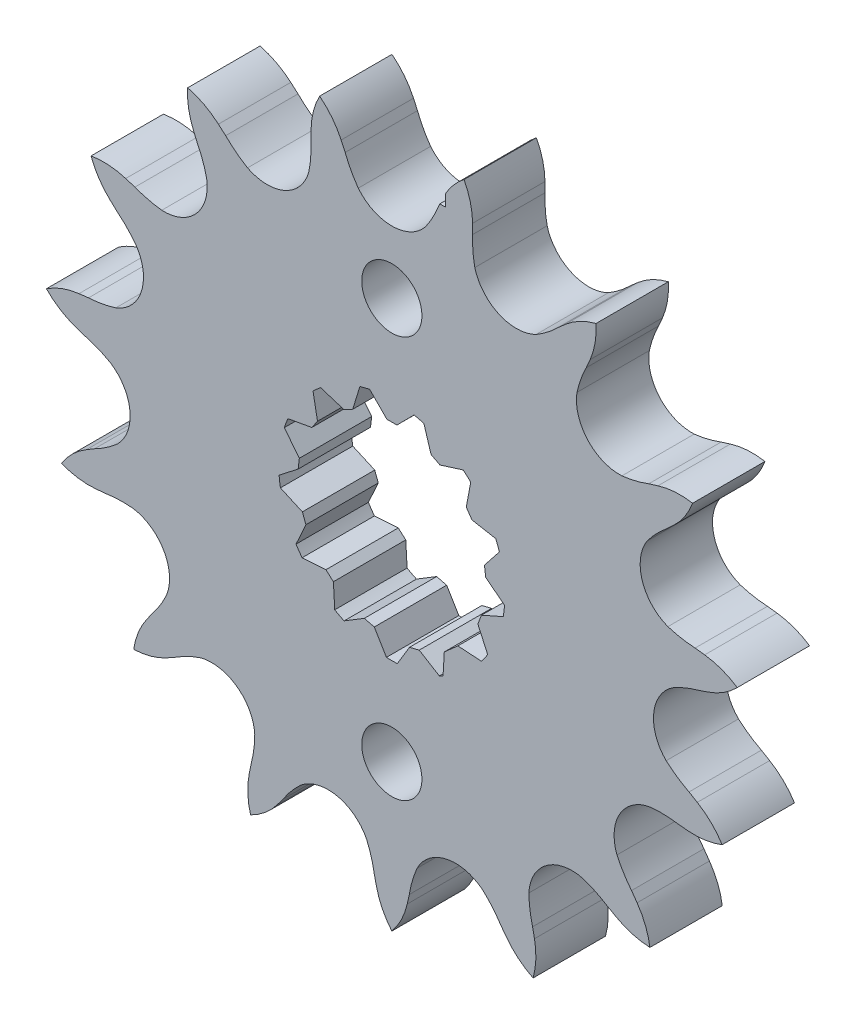
from build123d import *

# Parameters (mm, degrees)
BOSS_EXTRUDE1_DEPTH = 7.21
CUT_EXTRUDE1_DEPTH  = 8.21
SKETCH5_R           = 3
CUT_EXTRUDE2_DEPTH  = 8.21


with BuildPart() as part:
    # Sketch1 → Boss-Extrude1 (new body)
    with BuildSketch(Plane.XY):
        with BuildLine():
            ThreePointArc((-3.344051097, 27.836794078), (-4.073932005, 29.010531468), (-4.650860553, 30.266532682))
            Line((-4.650860553, 30.266532682), (-5.051693616, 31.13664581))
            ThreePointArc((-5.051693616, 31.13664581), (-5.962642461, 32.62154395), (-7.195527201, 33.852293925))
            ThreePointArc((-7.195527201, 33.852293925), (-7.821232343, 32.226488476), (-8.049463037, 30.499450249))
            Line((-8.049463037, 30.499450249), (-8.061735368, 29.541528859))
            ThreePointArc((-8.061735368, 29.541528859), (-8.077924105, 28.159456674), (-8.267301487, 26.790324903))
            ThreePointArc((-8.267301487, 26.790324903), (-9.550980171, 24.698310635), (-11.77, 23.649356079))
            ThreePointArc((-11.77, 23.649356079), (-13.106688219, 23.654582054), (-14.377186867, 24.070028667))
            ThreePointArc((-14.377186867, 24.070028667), (-15.521368261, 24.845421818), (-16.559280433, 25.758178042))
            Line((-16.559280433, 25.758178042), (-17.27936655, 26.390032443))
            ThreePointArc((-17.27936655, 26.390032443), (-18.715522214, 27.376038119), (-20.342409582, 27.998924767))
            ThreePointArc((-20.342409582, 27.998924767), (-20.252745021, 26.259180375), (-19.758794404, 24.588622661))
            Line((-19.758794404, 24.588622661), (-19.380384006, 23.70852632))
            ThreePointArc((-19.380384006, 23.70852632), (-18.833033751, 22.439356001), (-18.449162538, 21.11156517))
            ThreePointArc((-18.449162538, 21.11156517), (-19.500120221, 17.557987111), (-22.924376415, 16.141336631))
            ThreePointArc((-22.924376415, 16.141336631), (-24.285018938, 16.384313022), (-25.60445029, 16.796000412))
            Line((-25.60445029, 16.796000412), (-26.519280029, 17.080342721))
            ThreePointArc((-26.519280029, 17.080342721), (-28.232318151, 17.396966593), (-29.97190454, 17.304287155))
            ThreePointArc((-29.97190454, 17.304287155), (-29.182374094, 15.75142143), (-28.051650716, 14.426198835))
            Line((-28.051650716, 14.426198835), (-27.347988184, 13.776104195))
            ThreePointArc((-27.347988184, 13.776104195), (-26.33174077, 12.83928682), (-25.440995781, 11.782424026))
            ThreePointArc((-25.440995781, 11.782424026), (-24.955722988, 8.108605932), (-27.50773302, 5.421660852))
            ThreePointArc((-27.50773302, 5.421660852), (-28.849569217, 5.090207659), (-30.222378082, 4.929641724))
            Line((-30.222378082, 4.929641724), (-31.173769071, 4.817306572))
            ThreePointArc((-31.173769071, 4.817306572), (-32.867489797, 4.409801497), (-34.418984918, 3.617581088))
            ThreePointArc((-34.418984918, 3.617581088), (-33.066105573, 2.520098623), (-31.494121777, 1.769354172))
            Line((-31.494121777, 1.769354172), (-30.586876756, 1.461668503))
            ThreePointArc((-30.586876756, 1.461668503), (-29.277450593, 1.019188307), (-28.03384973, 0.415994728))
            ThreePointArc((-28.03384973, 0.415994728), (-26.096254534, -2.742826876), (-27.334752685, -6.235469343))
            ThreePointArc((-27.334752685, -6.235469343), (-28.425766889, -7.084040853), (-29.614582143, -7.789096802))
            Line((-29.614582143, -7.789096802), (-30.438030236, -8.278685647))
            ThreePointArc((-30.438030236, -8.278685647), (-31.819573866, -9.33985834), (-32.914710116, -10.694637613))
            ThreePointArc((-32.914710116, -10.694637613), (-31.232407002, -11.146972131), (-29.490973068, -11.193427902))
            Line((-29.490973068, -11.193427902), (-28.537016464, -11.105502953))
            ThreePointArc((-28.537016464, -11.105502953), (-27.160823231, -10.977137124), (-25.77939638, -11.022363837))
            ThreePointArc((-25.77939638, -11.022363837), (-22.724506595, -13.12), (-22.435345283, -16.814430241))
            ThreePointArc((-22.435345283, -16.814430241), (-23.086891225, -18.033394344), (-23.886155911, -19.161029729))
            Line((-23.886155911, -19.161029729), (-24.439279453, -19.943217909))
            ThreePointArc((-24.439279453, -19.943217909), (-25.269764541, -21.47457182), (-25.719182915, -23.157656313))
            ThreePointArc((-25.719182915, -23.157656313), (-23.998341523, -22.886630136), (-22.388567199, -22.220764602))
            Line((-22.388567199, -22.220764602), (-21.552846774, -21.752432057))
            ThreePointArc((-21.552846774, -21.752432057), (-20.347842784, -21.075415821), (-19.067451198, -20.55485556))
            ThreePointArc((-19.067451198, -20.55485556), (-15.42348502, -21.228605932), (-13.656662862, -24.486023396))
            ThreePointArc((-13.656662862, -24.486023396), (-13.756082331, -25.864610125), (-14.027596323, -27.219846544))
            Line((-14.027596323, -27.219846544), (-14.214755228, -28.159386615))
            ThreePointArc((-14.214755228, -28.159386615), (-14.350583359, -29.896136742), (-14.076575336, -31.616505856))
            ThreePointArc((-14.076575336, -31.616505856), (-12.614744777, -30.668981872), (-11.414974667, -29.405929233))
            Line((-11.414974667, -29.405929233), (-10.841994076, -28.638168044))
            ThreePointArc((-10.841994076, -28.638168044), (-10.016535466, -27.529563659), (-9.058570481, -26.533226022))
            ThreePointArc((-9.058570481, -26.533226022), (-5.455602767, -25.666593043), (-2.516619366, -27.923760657))
            ThreePointArc((-2.516619366, -27.923760657), (-2.046721832, -29.223599843), (-1.743537894, -30.572104607))
            Line((-1.743537894, -30.572104607), (-1.532370687, -31.506541555))
            ThreePointArc((-1.532370687, -31.506541555), (-0.950055943, -33.148388023), (0, -34.608574309))
            ThreePointArc((0, -34.608574309), (0.950055943, -33.148388023), (1.532370687, -31.506541555))
            Line((1.532370687, -31.506541555), (1.743537894, -30.572104607))
            ThreePointArc((1.743537894, -30.572104607), (2.046721832, -29.223599843), (2.516619366, -27.923760657))
            ThreePointArc((2.516619366, -27.923760657), (5.455602767, -25.666593043), (9.058570481, -26.533226022))
            ThreePointArc((9.058570481, -26.533226022), (10.016535466, -27.529563659), (10.841994076, -28.638168044))
            Line((10.841994076, -28.638168044), (11.414974667, -29.405929233))
            ThreePointArc((11.414974667, -29.405929233), (12.614744777, -30.668981872), (14.076575336, -31.616505856))
            ThreePointArc((14.076575336, -31.616505856), (14.350583359, -29.896136742), (14.214755228, -28.159386615))
            Line((14.214755228, -28.159386615), (14.027596323, -27.219846544))
            ThreePointArc((14.027596323, -27.219846544), (13.756082331, -25.864610125), (13.656662862, -24.486023396))
            ThreePointArc((13.656662862, -24.486023396), (15.42348502, -21.228605932), (19.067451198, -20.55485556))
            ThreePointArc((19.067451198, -20.55485556), (20.347842784, -21.075415821), (21.552846774, -21.752432057))
            Line((21.552846774, -21.752432057), (22.388567199, -22.220764602))
            ThreePointArc((22.388567199, -22.220764602), (23.998341523, -22.886630136), (25.719182915, -23.157656313))
            ThreePointArc((25.719182915, -23.157656313), (25.269764541, -21.47457182), (24.439279453, -19.943217909))
            Line((24.439279453, -19.943217909), (23.886155911, -19.161029729))
            ThreePointArc((23.886155911, -19.161029729), (23.086891225, -18.033394344), (22.435345283, -16.814430241))
            ThreePointArc((22.435345283, -16.814430241), (22.724506595, -13.12), (25.77939638, -11.022363837))
            ThreePointArc((25.77939638, -11.022363837), (27.160823231, -10.977137124), (28.537016464, -11.105502953))
            Line((28.537016464, -11.105502953), (29.490973068, -11.193427902))
            ThreePointArc((29.490973068, -11.193427902), (31.232407002, -11.146972131), (32.914710116, -10.694637613))
            ThreePointArc((32.914710116, -10.694637613), (31.819573866, -9.33985834), (30.438030236, -8.278685647))
            Line((30.438030236, -8.278685647), (29.614582143, -7.789096802))
            ThreePointArc((29.614582143, -7.789096802), (28.425766889, -7.084040853), (27.334752685, -6.235469343))
            ThreePointArc((27.334752685, -6.235469343), (26.096254534, -2.742826876), (28.03384973, 0.415994728))
            ThreePointArc((28.03384973, 0.415994728), (29.277450593, 1.019188307), (30.586876756, 1.461668503))
            Line((30.586876756, 1.461668503), (31.494121777, 1.769354172))
            ThreePointArc((31.494121777, 1.769354172), (33.066105573, 2.520098623), (34.418984918, 3.617581088))
            ThreePointArc((34.418984918, 3.617581088), (32.867489797, 4.409801497), (31.173769071, 4.817306572))
            Line((31.173769071, 4.817306572), (30.222378082, 4.929641724))
            ThreePointArc((30.222378082, 4.929641724), (28.849569217, 5.090207659), (27.50773302, 5.421660852))
            ThreePointArc((27.50773302, 5.421660852), (24.955722988, 8.108605932), (25.440995781, 11.782424026))
            ThreePointArc((25.440995781, 11.782424026), (26.33174077, 12.83928682), (27.347988184, 13.776104195))
            Line((27.347988184, 13.776104195), (28.051650716, 14.426198835))
            ThreePointArc((28.051650716, 14.426198835), (29.182374094, 15.75142143), (29.97190454, 17.304287155))
            ThreePointArc((29.97190454, 17.304287155), (28.232318151, 17.396966593), (26.519280029, 17.080342721))
            Line((26.519280029, 17.080342721), (25.60445029, 16.796000412))
            ThreePointArc((25.60445029, 16.796000412), (24.285018938, 16.384313022), (22.924376415, 16.141336631))
            ThreePointArc((22.924376415, 16.141336631), (19.500120221, 17.557987111), (18.449162538, 21.11156517))
            ThreePointArc((18.449162538, 21.11156517), (18.833033751, 22.439356001), (19.380384006, 23.70852632))
            Line((19.380384006, 23.70852632), (19.758794404, 24.588622661))
            ThreePointArc((19.758794404, 24.588622661), (20.252745021, 26.259180375), (20.342409582, 27.998924767))
            ThreePointArc((20.342409582, 27.998924767), (18.715522214, 27.376038119), (17.27936655, 26.390032443))
            Line((17.27936655, 26.390032443), (16.559280433, 25.758178042))
            ThreePointArc((16.559280433, 25.758178042), (15.521368261, 24.845421818), (14.377186867, 24.070028667))
            ThreePointArc((14.377186867, 24.070028667), (10.672769514, 23.971432809), (8.267301487, 26.790324903))
            ThreePointArc((8.267301487, 26.790324903), (8.077924105, 28.159456674), (8.061735368, 29.541528859))
            Line((8.061735368, 29.541528859), (8.049463037, 30.499450249))
            ThreePointArc((8.049463037, 30.499450249), (7.821232343, 32.226488476), (7.195527201, 33.852293925))
            ThreePointArc((7.195527201, 33.852293925), (6.163263436, 32.864830768), (5.34, 31.697402276))
            Line((5.34, 31.697402276), (5.34, 30.54))
            Line((5.34, 30.54), (4.776838129, 30.54))
            Line((4.776838129, 30.54), (4.650860553, 30.266532682))
            ThreePointArc((4.650860553, 30.266532682), (4.073932005, 29.010531468), (3.344051097, 27.836794078))
            ThreePointArc((3.344051097, 27.836794078), (0, 26.24), (-3.344051097, 27.836794078))
        make_face()
    extrude(amount=BOSS_EXTRUDE1_DEPTH)

    # Sketch4 → Cut-Extrude1 (cut, through all)
    with BuildSketch(Plane.XY.offset(7.21)):
        with BuildLine():
            Line((-1.746541595, -9.234175097), (-0.537166232, -11.251801112))
            ThreePointArc((-0.537166232, -11.251801112), (0.006157633, -11.264614414), (0.549467165, -11.25120712))
            Line((0.549467165, -11.25120712), (1.760269797, -9.234104476))
            Line((1.760269797, -9.234104476), (2.729465783, -8.995198416))
            Line((2.729465783, -8.995198416), (4.738009751, -10.219727953))
            ThreePointArc((4.738009751, -10.219727953), (4.922308476, -10.132248274), (5.10499275, -10.041445356))
            Line((5.10499275, -10.041445356), (5.227640368, -7.903145275))
            Line((5.227640368, -7.903145275), (6.581715487, -6.703490727))
            Line((6.581715487, -6.703490727), (8.938748699, -6.854950585))
            ThreePointArc((8.938748699, -6.854950585), (9.255633625, -6.420655887), (9.551436485, -5.971736506))
            Line((9.551436485, -5.971736506), (8.573753292, -3.817401412))
            Line((8.573753292, -3.817401412), (8.927703532, -2.884054642))
            Line((8.927703532, -2.884054642), (11.100480303, -1.915962649))
            ThreePointArc((11.100480303, -1.915962649), (11.178156674, -1.392978536), (11.231207225, -0.866925649))
            Line((11.231207225, -0.866925649), (9.350332828, 0.597196659))
            Line((9.350332828, 0.597196659), (9.22999233, 1.588123059))
            Line((9.22999233, 1.588123059), (10.716534232, 3.47094654))
            ThreePointArc((10.716534232, 3.47094654), (10.545533657, 3.960214099), (10.352208647, 4.441098056))
            Line((10.352208647, 4.441098056), (7.98639384, 4.867023628))
            Line((7.98639384, 4.867023628), (7.41933116, 5.688520361))
            Line((7.41933116, 5.688520361), (7.864104725, 8.065198863))
            ThreePointArc((7.864104725, 8.065198863), (7.491956336, 8.412025088), (7.104528841, 8.741695818))
            Line((7.104528841, 8.741695818), (4.794398311, 8.013913593))
            Line((4.794398311, 8.013913593), (3.910520676, 8.477785658))
            Line((3.910520676, 8.477785658), (3.195908154, 10.8017474))
            ThreePointArc((3.195908154, 10.8017474), (3.148865189, 10.815554717), (3.101762575, 10.829157158))
            Line((3.101762575, 10.829157158), (2.287122503, 11.029988508))
            ThreePointArc((2.287122503, 11.029988508), (2.254235043, 11.036756779), (2.221327555, 11.043426991))
            Line((2.221327555, 11.043426991), (0.505593949, 9.316951987))
            Line((0.505593949, 9.316951987), (-0.492612926, 9.316931884))
            Line((-0.492612926, 9.316931884), (-2.208702725, 11.045958903))
            ThreePointArc((-2.208702725, 11.045958903), (-2.208925871, 11.045914282), (-2.209149017, 11.045869655))
            Line((-2.209149019, 11.045869666), (-3.17615137, 10.807573192))
            ThreePointArc((-3.17615137, 10.807573192), (-3.177956591, 10.807042506), (-3.179761723, 10.806511519))
            Line((-3.179761723, 10.806511519), (-3.897505852, 8.477628417))
            Line((-3.897505852, 8.477628417), (-4.781364802, 8.013720752))
            Line((-4.781364802, 8.013720752), (-7.099622332, 8.745681138))
            ThreePointArc((-7.099622332, 8.745681138), (-7.143700393, 8.709714147), (-7.187596247, 8.673525005))
            Line((-7.187596247, 8.673525005), (-7.743147404, 8.181396219))
            ThreePointArc((-7.743147404, 8.181396219), (-7.797607791, 8.129507276), (-7.851720464, 8.07725582))
            Line((-7.851720464, 8.07725582), (-7.40620399, 5.688221799))
            Line((-7.40620399, 5.688221799), (-7.973233582, 4.866702226))
            Line((-7.973233582, 4.866702226), (-10.352734629, 4.439871792))
            ThreePointArc((-10.352734629, 4.439871792), (-10.543286211, 3.966193602), (-10.712178092, 3.484367424))
            Line((-10.712178092, 3.484367424), (-9.216700007, 1.587751572))
            Line((-9.216700007, 1.587751572), (-9.337000594, 0.596820326))
            Line((-9.337000594, 0.596820326), (-11.230561697, -0.875248413))
            ThreePointArc((-11.230561697, -0.875248413), (-11.178137153, -1.393135173), (-11.101843629, -1.908047133))
            Line((-11.101843629, -1.908047133), (-8.914231084, -2.884413951))
            Line((-8.914231084, -2.884413951), (-8.560243252, -3.817746464))
            Line((-8.560243252, -3.817746464), (-9.544474508, -5.98285736))
            ThreePointArc((-9.544474508, -5.98285736), (-9.252019832, -6.425862187), (-8.939019569, -6.85459736))
            Line((-8.939019569, -6.85459736), (-6.568089206, -6.703755543))
            Line((-6.568089206, -6.703755543), (-5.820907301, -7.365674092))
            Line((-5.820907301, -7.365674092), (-5.687165981, -9.723565134))
            ThreePointArc((-5.687165981, -9.723565134), (-5.226618942, -9.978678783), (-4.754654688, -10.211994645))
            Line((-4.754654688, -10.211994645), (-2.744487348, -8.988224879))
            Line((-2.744487348, -8.988224879), (-1.746541595, -9.234175097))
        make_face()
    extrude(amount=-CUT_EXTRUDE1_DEPTH, mode=Mode.SUBTRACT)

    # Sketch5 → Cut-Extrude2 (cut, through all)
    with BuildSketch(Plane.XY.offset(7.21)):
        with Locations((0, 20)):
            Circle(SKETCH5_R)
        with Locations((0, -20)):
            Circle(SKETCH5_R)
    extrude(amount=-CUT_EXTRUDE2_DEPTH, mode=Mode.SUBTRACT)


solid = part.part
